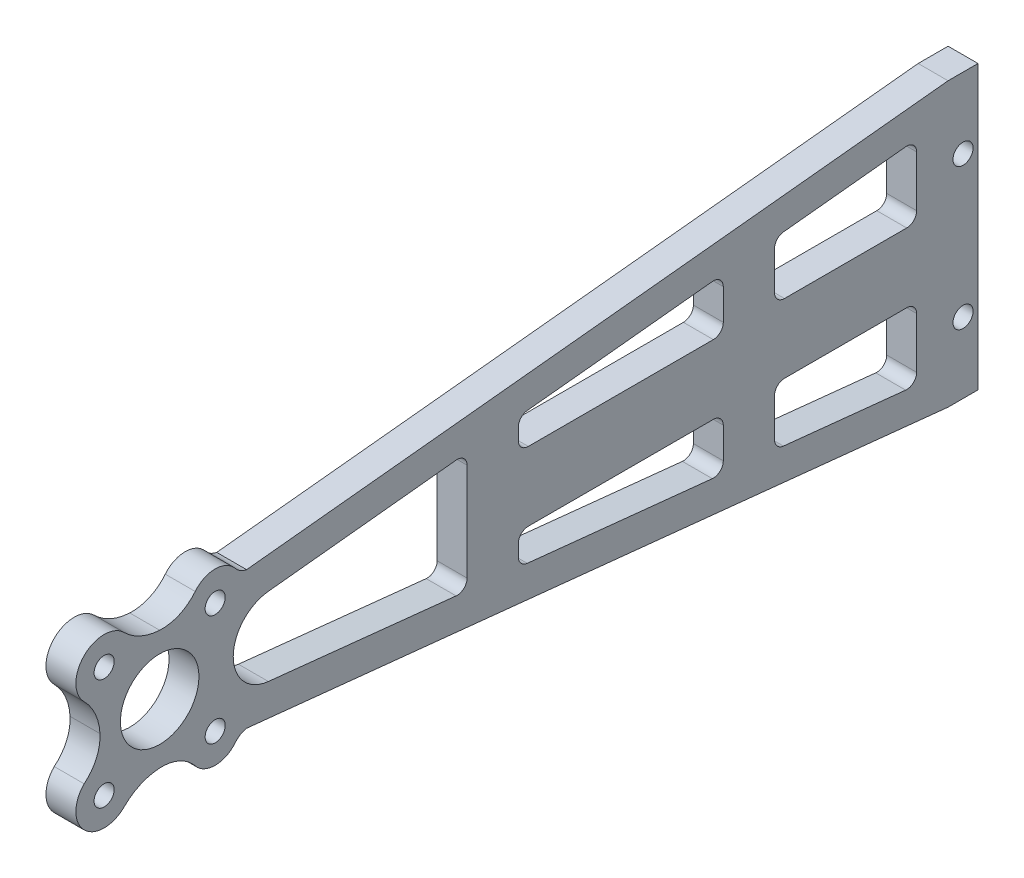
from build123d import *

# Parameters (mm, degrees)
SKETCH1_R            = 6.25
BOSS_EXTRUDE1_DEPTH  = 2.3815
M3_CLEARANCE_HOLE1_D = 3.2
M3_CLEARANCE_HOLE2_D = 3.2


with BuildPart() as part:
    # Sketch1 → Boss-Extrude1 (new body, symmetric)
    with BuildSketch(Plane(origin=(0, 0, 0), x_dir=(0, 0, -1), z_dir=(1, 0, 0))):
        with BuildLine():
            Line((13.837853408, 10.933433942), (125.499999966, 22.5))
            Line((125.499999966, 22.5), (130.262999966, 22.5))
            Line((130.262999966, 22.5), (130.262999966, -22.5))
            Line((130.262999966, -22.5), (125.499999966, -22.5))
            Line((125.499999966, -22.5), (13.842307627, -10.933864535))
            ThreePointArc((13.842307627, -10.933864535), (12.834192522, -11.314170817), (12.02081528, -12.02081528))
            ThreePointArc((12.02081528, -12.02081528), (8.840593, -13.543231212), (5.659233624, -12.023192877))
            ThreePointArc((5.659233624, -12.023192877), (3.133291337, -10.08048914), (0, -9.5))
            ThreePointArc((0, -9.5), (-3.061848318, -10.236700307), (-5.656913672, -12.020874702))
            ThreePointArc((-5.656913672, -12.020874702), (-12.020874702, -12.020874704), (-12.020874704, -5.656913674))
            ThreePointArc((-12.020874704, -5.656913674), (-10.079850186, -3.131745006), (-9.500000034, 0))
            ThreePointArc((-9.500000034, 0), (-10.236707938, 3.061753973), (-12.020757217, 5.656796188))
            ThreePointArc((-12.020757217, 5.656796188), (-12.02045467, 12.020757197), (-5.65649366, 12.02045465))
            ThreePointArc((-5.65649366, 12.02045465), (-3.061652792, 10.236409392), (0, 9.5))
            ThreePointArc((0, 9.5), (3.130793061, 10.079739971), (5.655645869, 12.019606441))
            ThreePointArc((5.655645869, 12.019606441), (8.837941978, 13.539821179), (12.02081528, 12.02081528))
            ThreePointArc((12.02081528, 12.02081528), (12.832791387, 11.315799207), (13.837853408, 10.933433942))
        make_face()
        Circle(SKETCH1_R, mode=Mode.SUBTRACT)
        with BuildLine():
            Line((17.302023212, 6.215300033), (47.183954034, 9.358065674))
            ThreePointArc((47.183954034, 9.358065674), (48.412204848, 8.959051834), (48.9375, 7.779273418))
            Line((48.9375, 7.779273418), (48.9375, -7.779269087))
            ThreePointArc((48.9375, -7.779269087), (48.412206576, -8.959045947), (47.183958659, -9.358061829))
            Line((47.183958659, -9.358061829), (17.302047548, -6.21538676))
            ThreePointArc((17.302047548, -6.21538676), (11.709307369, -5.4312e-05), (17.302023212, 6.215300033))
        make_face(mode=Mode.SUBTRACT)
        with BuildLine():
            Line((57.09375, 8.955806876), (57.09375, 7.0875))
            ThreePointArc((57.09375, 7.0875), (57.558717985, 5.964967985), (58.68125, 5.5))
            Line((58.68125, 5.5), (88.13125, 5.5))
            ThreePointArc((88.13125, 5.5), (89.253782015, 5.964967985), (89.71875, 7.0875))
            Line((89.71875, 7.0875), (89.71875, 12.006396363))
            ThreePointArc((89.71875, 12.006396363), (89.194380816, 13.185340432), (87.967683395, 13.585447412))
            Line((87.967683395, 13.585447412), (58.517683395, 10.534857925))
            ThreePointArc((58.517683395, 10.534857925), (57.502305931, 10.018937692), (57.09375, 8.955806876))
        make_face(mode=Mode.SUBTRACT)
        with BuildLine():
            Line((58.68125, -5.5), (88.13125, -5.5))
            ThreePointArc((88.13125, -5.5), (89.253782015, -5.964967985), (89.71875, -7.0875))
            Line((89.71875, -7.0875), (89.71875, -12.006377313))
            ThreePointArc((89.71875, -12.006377313), (89.194380958, -13.185321253), (87.967683776, -13.585428401))
            Line((87.967683776, -13.585428401), (58.517683776, -10.534846102))
            ThreePointArc((58.517683776, -10.534846102), (57.502306059, -10.018925972), (57.09375, -8.955795013))
            Line((57.09375, -8.955795013), (57.09375, -7.0875))
            ThreePointArc((57.09375, -7.0875), (57.558717985, -5.964967985), (58.68125, -5.5))
        make_face(mode=Mode.SUBTRACT)
        with BuildLine():
            Line((99.298933395, 14.759199267), (118.74893336, 16.773934935))
            ThreePointArc((118.74893336, 16.773934935), (119.975630782, 16.373827955), (120.499999966, 15.194883886))
            Line((120.499999966, 15.194883886), (120.499999966, 7.0875))
            ThreePointArc((120.499999966, 7.0875), (120.035031981, 5.964967985), (118.912499966, 5.5))
            Line((118.912499966, 5.5), (99.4625, 5.5))
            ThreePointArc((99.4625, 5.5), (98.339967985, 5.964967985), (97.875, 7.0875))
            Line((97.875, 7.0875), (97.875, 13.180148218))
            ThreePointArc((97.875, 13.180148218), (98.283555931, 14.243279034), (99.298933395, 14.759199267))
        make_face(mode=Mode.SUBTRACT)
        with BuildLine():
            Line((118.912499966, -5.5), (99.4625, -5.5))
            ThreePointArc((99.4625, -5.5), (98.339967985, -5.964967985), (97.875, -7.0875))
            Line((97.875, -7.0875), (97.875, -13.180126402))
            ThreePointArc((97.875, -13.180126402), (98.283556059, -14.24325736), (99.298933776, -14.759177491))
            Line((99.298933776, -14.759177491), (118.748933742, -16.773908412))
            ThreePointArc((118.748933742, -16.773908412), (119.975630924, -16.373801264), (120.499999966, -15.194857323))
            Line((120.499999966, -15.194857323), (120.499999966, -7.0875))
            ThreePointArc((120.499999966, -7.0875), (120.035031981, -5.964967985), (118.912499966, -5.5))
        make_face(mode=Mode.SUBTRACT)
    extrude(amount=BOSS_EXTRUDE1_DEPTH, both=True)

    # M3 Clearance Hole1 (through all)
    with Locations(Plane(origin=(2.3815, 0, 0), x_dir=(0, 0, -1), z_dir=(1, 0, 0))):
        with Locations((127.881499966, 11.25), (127.881499966, -11.25)):
            Hole(M3_CLEARANCE_HOLE1_D / 2)

    # M3 Clearance Hole2 (through all)
    with Locations(Plane(origin=(2.3815, 0, 0), x_dir=(0, 0, -1), z_dir=(1, 0, 0))):
        with Locations((-8.838834765, 8.838834765), (8.838834765, 8.838834765), (8.838834765, -8.838834765), (-8.838834765, -8.838834765)):
            Hole(M3_CLEARANCE_HOLE2_D / 2)


solid = part.part
